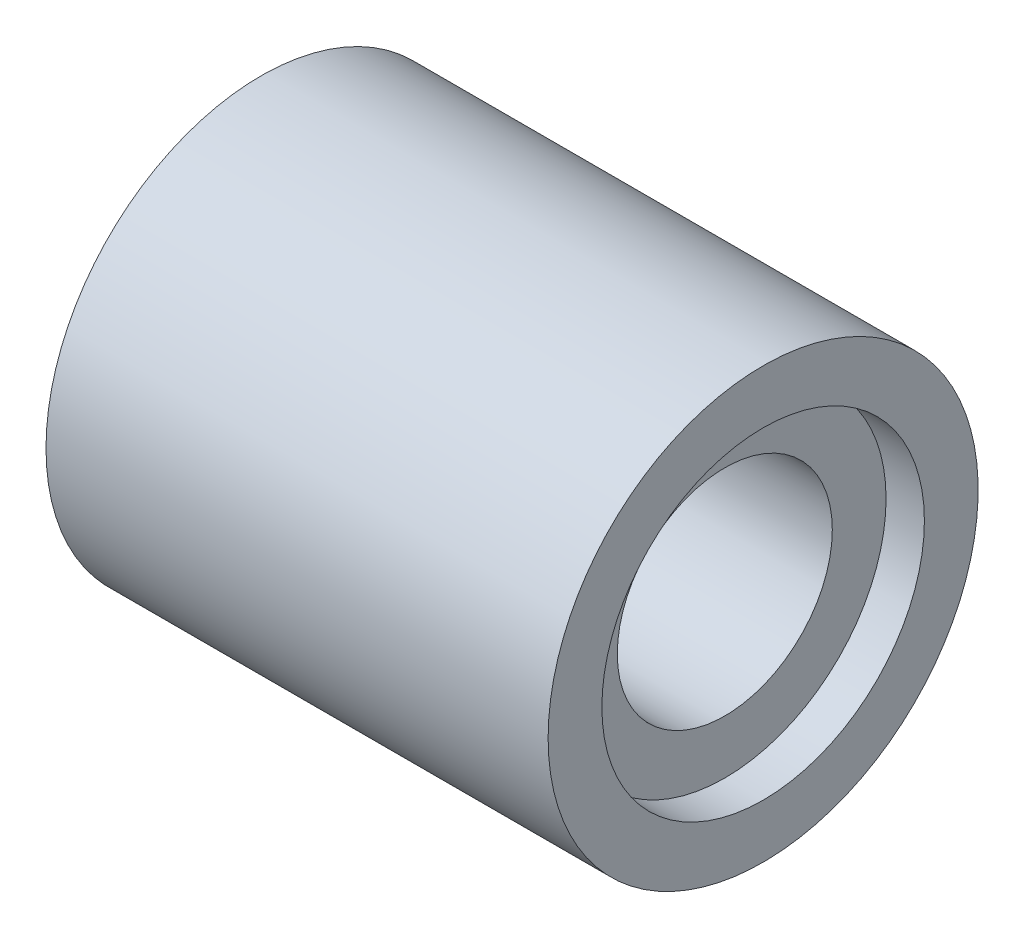
from build123d import *


with BuildPart() as part:
    # Sketch1 → Revolve1 (revolve)
    with BuildSketch(Plane.XY):
        Polygon((-25.353512272, 20), (-25.353512272, 15), (-21.368212172, 15), (-21.368212172, 10), (17.785613365, 10), (17.785613365, 15), (21.35140819, 15), (21.35140819, 20), align=None)
    revolve(axis=Axis((-29.383970125, 0, 0), (1, 0, 0)))


solid = part.part
